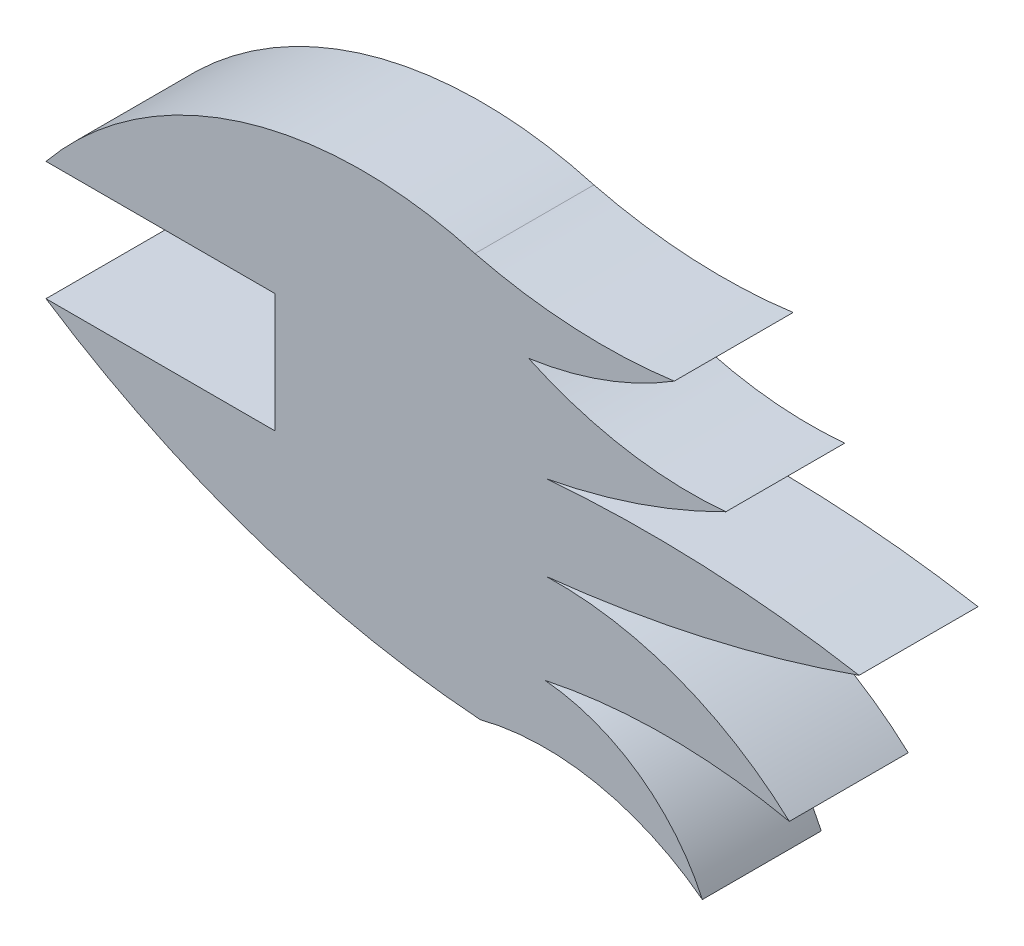
from build123d import *

# Parameters (mm, degrees)
BOSS_EXTRUDE1_DEPTH = 1.524


with BuildPart() as part:
    # Sketch1 → Boss-Extrude1 (new body)
    with BuildSketch(Plane.XY):
        with BuildLine():
            Line((23.699745488, 1.524), (23.699745488, 0))
            Line((23.699745488, 0), (20.767560847, 0))
            ThreePointArc((20.767560847, 0), (23.42913794, -1.301543103), (26.332873234, -1.890039844))
            ThreePointArc((26.332873234, -1.890039844), (27.822037462, -1.85074691), (29.179825721, -2.463580554))
            ThreePointArc((29.179825721, -2.463580554), (28.364487323, -1.477962315), (27.163224831, -1.038430246))
            ThreePointArc((27.163224831, -1.038430246), (28.728924057, -0.875087412), (30.294623282, -1.038430246))
            ThreePointArc((30.294623282, -1.038430246), (28.84920273, -0.154192624), (27.177608147, 0.123094766))
            ThreePointArc((27.177608147, 0.123094766), (29.209666297, 0.459343802), (31.188707793, 1.03006133))
            ThreePointArc((31.188707793, 1.03006133), (29.188863831, 1.247682511), (27.177608147, 1.207865103))
            ThreePointArc((27.177608147, 1.207865103), (28.357122869, 1.517990015), (29.481047207, 1.991515643))
            ThreePointArc((29.481047207, 1.991515643), (28.187668321, 2.044064099), (26.952298477, 2.430653848))
            ThreePointArc((26.952298477, 2.430653848), (27.921180331, 2.673808335), (28.819454547, 3.110797561))
            ThreePointArc((28.819454547, 3.110797561), (27.535947123, 3.059263221), (26.265619678, 3.249828897))
            ThreePointArc((26.265619678, 3.249828897), (23.258369024, 3.209542673), (20.767560847, 1.524))
            Line((20.767560847, 1.524), (23.699745488, 1.524))
        make_face()
    extrude(amount=BOSS_EXTRUDE1_DEPTH)


solid = part.part
